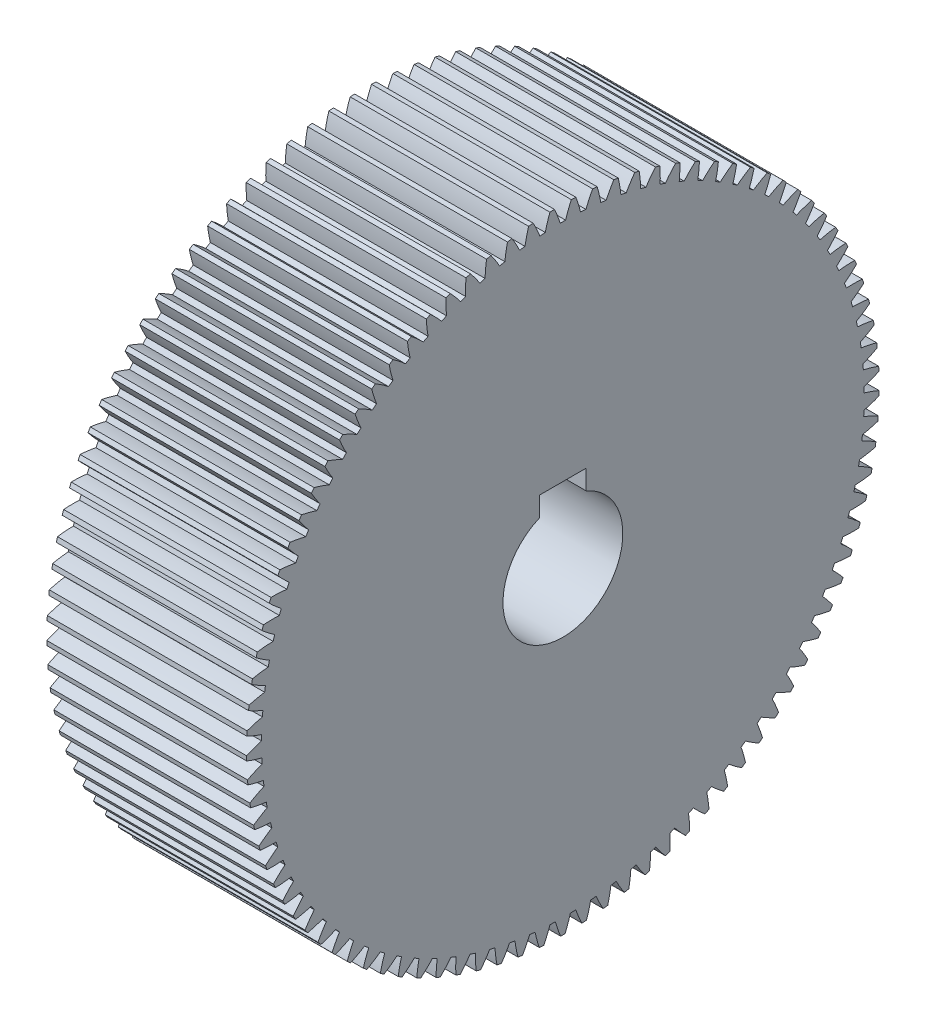
from build123d import *

# Parameters (mm, degrees)
BASPROSKE_W        = 60
BASPROSKE_H        = 95
TOOTHCUT_DEPTH     = 148.139389696
TEETHCUTS_COUNT    = 93
TEETHCUTS_ANGLE    = 356.129032258
BORSKE_R           = 0.4
BORE_DEPTH         = 60.0000508
CUT_EXTRUDE1_DEPTH = 148.136494826


with BuildPart() as part:
    # BasProSke → Base-Revolve (revolve)
    with BuildSketch(Plane(origin=(0, 0, 0), x_dir=(1, 0, 0), z_dir=(0, 1, 0)), mode=Mode.PRIVATE) as base_revolve_sk:
        with Locations((30, 47.5)):
            Rectangle(BASPROSKE_W, BASPROSKE_H)
    revolve(base_revolve_sk.sketch.rotate(Axis((-10, 0, 0), (1, 0, 0)), 180), axis=Axis((-10, 0, 0), (1, 0, 0)))

    # TooCutSke → ToothCut (cut, through all)
    with BuildSketch(Plane(origin=(0, 0, 0), x_dir=(0, 0, -1), z_dir=(1, 0, 0))):
        with BuildLine():
            ThreePointArc((0.817899856, 90.495303971), (0, 90.499), (-0.817899856, 90.495303971))
            ThreePointArc((-0.817899856, 90.495303971), (-1.605530461, 92.771259662), (-2.538782264, 94.991479775))
            ThreePointArc((-2.538782264, 94.991479775), (0, 95.0254), (2.538782264, 94.991479775))
            ThreePointArc((2.538782264, 94.991479775), (1.605530461, 92.771259662), (0.817899856, 90.495303971))
        make_face()
    toothcut = extrude(amount=TOOTHCUT_DEPTH, mode=Mode.SUBTRACT)

    # TeethCuts: ToothCut ×93 about axis
    teethcuts_axis = Axis((-10, 0, 0), (1, 0, 0))
    for i in range(1, TEETHCUTS_COUNT):
        add(toothcut.rotate(teethcuts_axis, i * TEETHCUTS_ANGLE / (TEETHCUTS_COUNT - 1)), mode=Mode.SUBTRACT)

    # BorSke → Bore (cut, symmetric)
    with BuildSketch(Plane(origin=(0, 0, 0), x_dir=(0, 0, -1), z_dir=(1, 0, 0))):
        with Locations(Location((0, 0, 0), (0, 0, 180))):
            Circle(BORSKE_R)
    extrude(amount=BORE_DEPTH, both=True, mode=Mode.SUBTRACT)

    # Sketch1 → Cut-Extrude1 (cut, through all)
    with BuildSketch(Plane(origin=(60, 0, 0), x_dir=(0, 0, -1), z_dir=(1, 0, 0))):
        with BuildLine():
            Line((-7, 22.9), (7, 22.9))
            Line((7, 22.9), (7, 16.983123952))
            ThreePointArc((7, 16.983123952), (0, -17.6), (-7, 16.983123952))
            Line((-7, 16.983123952), (-7, 22.9))
        make_face()
    extrude(amount=-CUT_EXTRUDE1_DEPTH, mode=Mode.SUBTRACT)


solid = part.part
